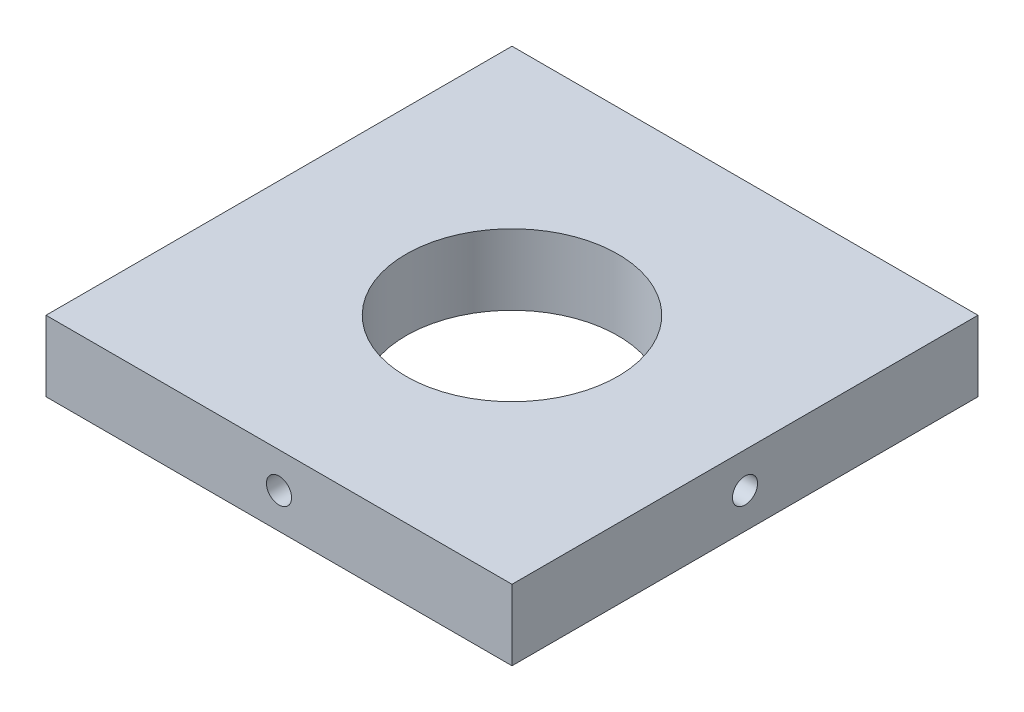
from build123d import *

# Parameters (mm, degrees)
SKETCH1_W                 = 33
SKETCH1_H                 = 33
SKETCH1_R                 = 7.5
BOSS_EXTRUDE1_DEPTH       = 5
F_2_56_TAPPED_HOLE4_D     = 1.778
F_2_56_TAPPED_HOLE4_DEPTH = 6.46583491
F_2_56_TAPPED_HOLE4_TIP   = 0.53416509
F_2_56_TAPPED_HOLE5_D     = 1.778
F_2_56_TAPPED_HOLE5_DEPTH = 7.46583491
F_2_56_TAPPED_HOLE5_TIP   = 0.53416509
F_2_56_TAPPED_HOLE6_D     = 1.778
F_2_56_TAPPED_HOLE6_DEPTH = 7.46583491
F_2_56_TAPPED_HOLE6_TIP   = 0.53416509
F_2_56_TAPPED_HOLE7_D     = 1.778
F_2_56_TAPPED_HOLE7_DEPTH = 7.46583491
F_2_56_TAPPED_HOLE7_TIP   = 0.53416509


with BuildPart() as part:
    # Sketch1 → Boss-Extrude1 (new body)
    with BuildSketch(Plane(origin=(0, 0, 0), x_dir=(1, 0, 0), z_dir=(0, 1, 0))):
        Rectangle(SKETCH1_W, SKETCH1_H)
        Circle(SKETCH1_R, mode=Mode.SUBTRACT)
    extrude(amount=BOSS_EXTRUDE1_DEPTH)

    # #2-56 Tapped Hole4
    with Locations(Plane.XY.offset(16.5)):
        with Locations((0, 2.5)):
            Hole(F_2_56_TAPPED_HOLE4_D / 2, depth=F_2_56_TAPPED_HOLE4_DEPTH)
            with Locations((0, 0, -(F_2_56_TAPPED_HOLE4_DEPTH + F_2_56_TAPPED_HOLE4_TIP / 2))):  # 118° drill point
                Cone(0, F_2_56_TAPPED_HOLE4_D / 2, F_2_56_TAPPED_HOLE4_TIP, mode=Mode.SUBTRACT)

    # #2-56 Tapped Hole5
    with Locations(Plane(origin=(0, 0, -16.5), x_dir=(-1, 0, 0), z_dir=(0, 0, -1))):
        with Locations((0, 2.5)):
            Hole(F_2_56_TAPPED_HOLE5_D / 2, depth=F_2_56_TAPPED_HOLE5_DEPTH)
            with Locations((0, 0, -(F_2_56_TAPPED_HOLE5_DEPTH + F_2_56_TAPPED_HOLE5_TIP / 2))):  # 118° drill point
                Cone(0, F_2_56_TAPPED_HOLE5_D / 2, F_2_56_TAPPED_HOLE5_TIP, mode=Mode.SUBTRACT)

    # #2-56 Tapped Hole6
    with Locations(Plane(origin=(16.5, 0, 0), x_dir=(0, 0, -1), z_dir=(1, 0, 0))):
        with Locations((0, 2.5)):
            Hole(F_2_56_TAPPED_HOLE6_D / 2, depth=F_2_56_TAPPED_HOLE6_DEPTH)
            with Locations((0, 0, -(F_2_56_TAPPED_HOLE6_DEPTH + F_2_56_TAPPED_HOLE6_TIP / 2))):  # 118° drill point
                Cone(0, F_2_56_TAPPED_HOLE6_D / 2, F_2_56_TAPPED_HOLE6_TIP, mode=Mode.SUBTRACT)

    # #2-56 Tapped Hole7
    with Locations(Plane.ZY.offset(16.5)):
        with Locations((0, 2.5)):
            Hole(F_2_56_TAPPED_HOLE7_D / 2, depth=F_2_56_TAPPED_HOLE7_DEPTH)
            with Locations((0, 0, -(F_2_56_TAPPED_HOLE7_DEPTH + F_2_56_TAPPED_HOLE7_TIP / 2))):  # 118° drill point
                Cone(0, F_2_56_TAPPED_HOLE7_D / 2, F_2_56_TAPPED_HOLE7_TIP, mode=Mode.SUBTRACT)


solid = part.part
